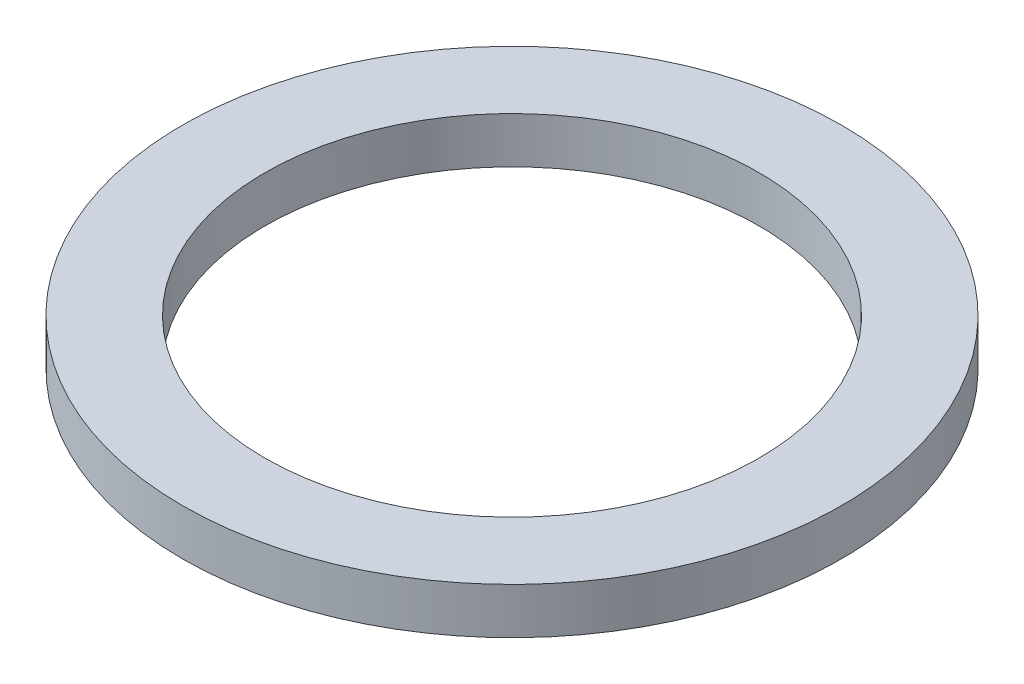
from build123d import *

# Parameters (mm, degrees)
SKETCH1_R           = 8
SKETCH1_R_2         = 6
BOSS_EXTRUDE1_DEPTH = 1.12


with BuildPart() as part:
    # Sketch1 → Boss-Extrude1 (new body)
    with BuildSketch(Plane(origin=(0, 0, 0), x_dir=(1, 0, 0), z_dir=(0, 1, 0))):
        Circle(SKETCH1_R)
        Circle(SKETCH1_R_2, mode=Mode.SUBTRACT)
    extrude(amount=BOSS_EXTRUDE1_DEPTH)


solid = part.part
